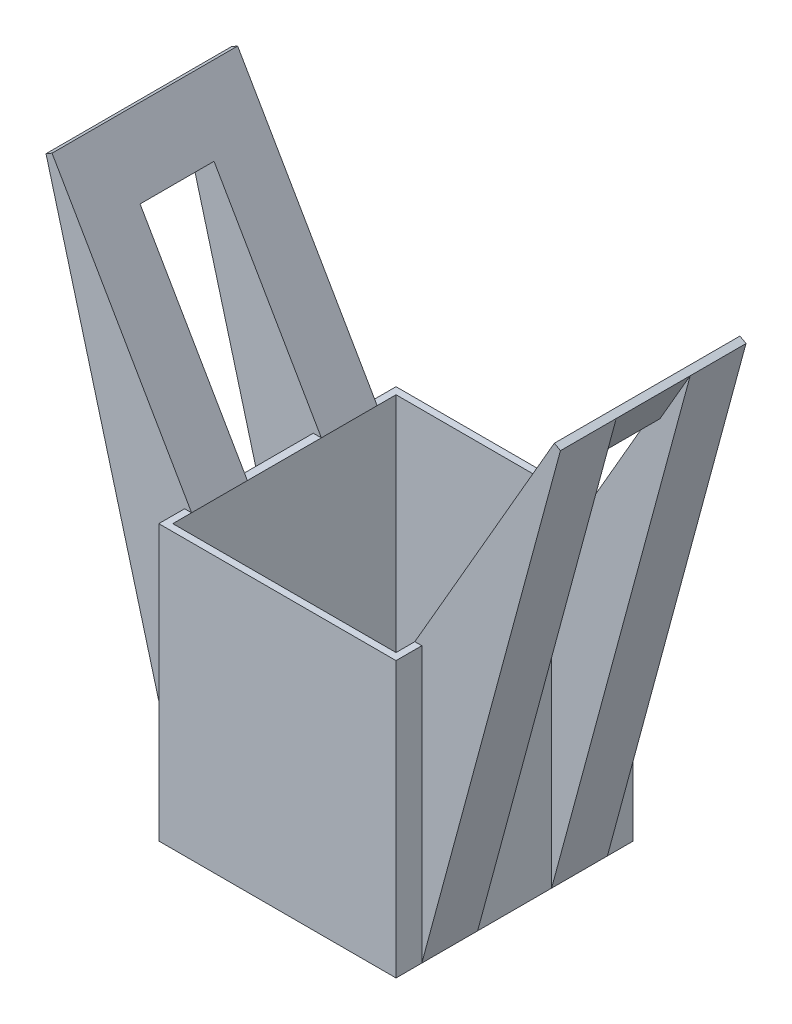
from build123d import *

# Parameters (mm, degrees)
SKIZZE1_W                        = 17
SKIZZE1_H                        = 17
SKIZZE1_W_2                      = 16
SKIZZE1_H_2                      = 16
AUFSATZ_LINEAR_AUSTRAGEN1_DEPTH  = 19.7
SKIZZE10_W                       = 13.3
SKIZZE10_H                       = 20
AUFSATZ_LINEAR_AUSTRAGEN5_DEPTH  = 0.5
SKIZZE11_W                       = 5.3
SKIZZE11_H                       = 13.320508076
SCHNITT_LINEAR_AUSTRAGEN14_DEPTH = 11.433012702
AUFSATZ_LINEAR_AUSTRAGEN6_DEPTH  = 4
AUFSATZ_LINEAR_AUSTRAGEN7_DEPTH  = 4


with BuildPart() as part:
    # Skizze1 → Aufsatz-Linear austragen1 (new body)
    with BuildSketch(Plane(origin=(0, 0, 0), x_dir=(1, 0, 0), z_dir=(0, 1, 0))):
        Rectangle(SKIZZE1_W, SKIZZE1_H)
        Rectangle(SKIZZE1_W_2, SKIZZE1_H_2, mode=Mode.SUBTRACT)
    extrude(amount=AUFSATZ_LINEAR_AUSTRAGEN1_DEPTH)

    # Skizze10 → Aufsatz-Linear austragen5 (add)
    with BuildSketch(Plane(origin=(-2.530350227, 1.460898385, 0), x_dir=(0, 0, -1), z_dir=(0.866025404, -0.5, 0))):
        with Locations((-0.00194728, 31.060700455)):
            Rectangle(SKIZZE10_W, SKIZZE10_H)
    aufsatz_linear_austragen5 = extrude(amount=AUFSATZ_LINEAR_AUSTRAGEN5_DEPTH)

    # Skizze11 → Schnitt-Linear austragen14 (cut, through all)
    with BuildSketch(Plane.ZY.offset(-8)):
        with Locations((0.00194728, 26.360254038)):
            Rectangle(SKIZZE11_W, SKIZZE11_H)
    schnitt_linear_austragen14 = extrude(amount=-SCHNITT_LINEAR_AUSTRAGEN14_DEPTH, mode=Mode.SUBTRACT)

    # Skizze12 → Aufsatz-Linear austragen6 (add)
    with BuildSketch(Plane.XY.offset(6.65194728)):
        Polygon((18.433012702, 36.770508076), (8.5, 0), (8.5, 19.7), align=None)
    aufsatz_linear_austragen6 = extrude(amount=-AUFSATZ_LINEAR_AUSTRAGEN6_DEPTH)

    # Skizze13 → Aufsatz-Linear austragen7 (add)
    with BuildSketch(Plane(origin=(0, 0, -6.64805272), x_dir=(-1, 0, 0), z_dir=(0, 0, -1))):
        Polygon((-18.433012702, 36.770508076), (-8.5, 19.7), (-8.5, 0), align=None)
    aufsatz_linear_austragen7 = extrude(amount=-AUFSATZ_LINEAR_AUSTRAGEN7_DEPTH)

    # Spiegeln6: Aufsatz-Linear austragen5, Schnitt-Linear austragen14, Aufsatz-Linear austragen6, Aufsatz-Linear austragen7 across plane
    add(aufsatz_linear_austragen5.mirror(Plane(origin=(0, 0, 0), x_dir=(0, 0, 1), z_dir=(1, 0, 0))))
    add(schnitt_linear_austragen14.mirror(Plane(origin=(0, 0, 0), x_dir=(0, 0, 1), z_dir=(1, 0, 0))), mode=Mode.SUBTRACT)
    add(aufsatz_linear_austragen6.mirror(Plane(origin=(0, 0, 0), x_dir=(0, 0, 1), z_dir=(1, 0, 0))))
    add(aufsatz_linear_austragen7.mirror(Plane(origin=(0, 0, 0), x_dir=(0, 0, 1), z_dir=(1, 0, 0))))


solid = part.part
